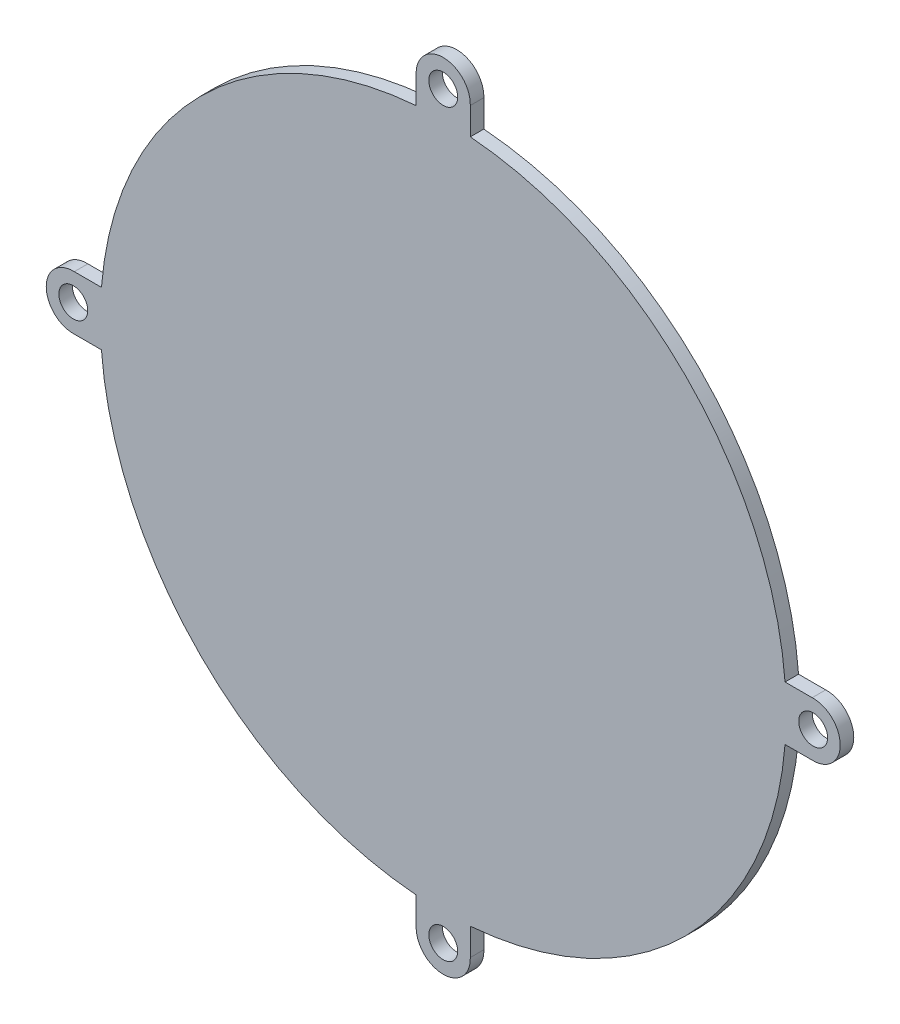
from build123d import *

# Parameters (mm, degrees)
SKETCH1_R           = 1.6
BOSS_EXTRUDE1_DEPTH = 1.5


with BuildPart() as part:
    # Sketch1 → Boss-Extrude1 (new body)
    with BuildSketch(Plane.XY):
        with BuildLine():
            Line((-40.890243902, 2.997991594), (-37.881552851, 2.997991594))
            ThreePointArc((-37.881552851, 2.997991594), (-26.870057685, 26.870057685), (-2.997991594, 37.881552851))
            Line((-2.997991594, 37.881552851), (-2.997991594, 40.890243902))
            ThreePointArc((-2.997991594, 40.890243902), (0, 44), (2.997991594, 40.890243902))
            Line((2.997991594, 40.890243902), (2.997991594, 37.881552851))
            ThreePointArc((2.997991594, 37.881552851), (26.870057685, 26.870057685), (37.881552851, 2.997991594))
            Line((37.881552851, 2.997991594), (40.890243902, 2.997991594))
            ThreePointArc((40.890243902, 2.997991594), (44, 0), (40.890243902, -2.997991594))
            Line((40.890243902, -2.997991594), (37.881552851, -2.997991594))
            ThreePointArc((37.881552851, -2.997991594), (26.870057685, -26.870057685), (2.997991594, -37.881552851))
            Line((2.997991594, -37.881552851), (2.997991594, -40.890243902))
            ThreePointArc((2.997991594, -40.890243902), (0, -44), (-2.997991594, -40.890243902))
            Line((-2.997991594, -40.890243902), (-2.997991594, -37.881552851))
            ThreePointArc((-2.997991594, -37.881552851), (-26.870057685, -26.870057685), (-37.881552851, -2.997991594))
            Line((-37.881552851, -2.997991594), (-40.890243902, -2.997991594))
            ThreePointArc((-40.890243902, -2.997991594), (-44, 0), (-40.890243902, 2.997991594))
        make_face()
        with Locations((0, 41)):
            Circle(SKETCH1_R, mode=Mode.SUBTRACT)
        with Locations((41, 0)):
            Circle(SKETCH1_R, mode=Mode.SUBTRACT)
        with Locations((0, -41)):
            Circle(SKETCH1_R, mode=Mode.SUBTRACT)
        with Locations((-41, 0)):
            Circle(SKETCH1_R, mode=Mode.SUBTRACT)
    extrude(amount=BOSS_EXTRUDE1_DEPTH)


solid = part.part
